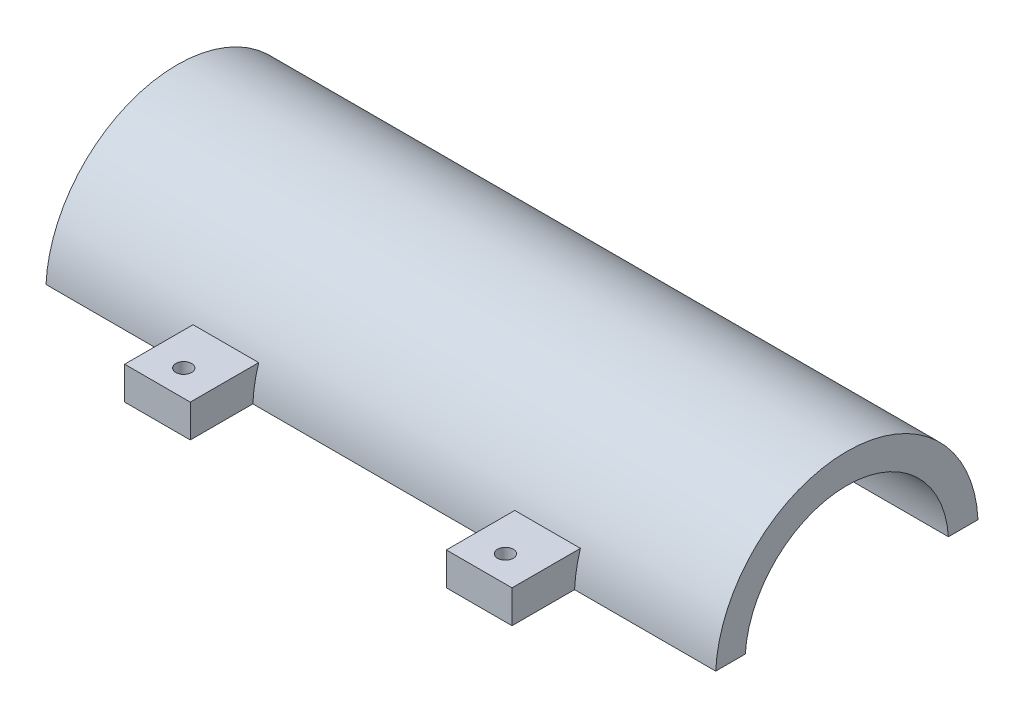
from build123d import *
from build123d.topology import SkipClean

# Parameters (mm, degrees)
SKETCH1_W                = 34
SKETCH1_H                = 30
BOSS_EXTRUDE2_DEPTH      = 51
SKETCH3_R                = 2.55
CUT_EXTRUDE3_DEPTH       = 10
SKETCH5_R                = 7.75
CUT_EXTRUDE4_DEPTH       = 51
SKETCH6_W                = 7
SKETCH6_H                = 30
CUT_EXTRUDE6_DEPTH       = 51
CUT_EXTRUDE7_DEPTH       = 51
CUT_EXTRUDE9_DEPTH       = 1.5
CUT_EXTRUDE9_DEPTH_BACK  = 1.5
BOSS_EXTRUDE5_DEPTH      = 51
CUT_EXTRUDE10_DEPTH      = 13
CUT_EXTRUDE11_START      = -13
CUT_EXTRUDE11_DEPTH      = 13
SKETCH13_W               = 2
SKETCH13_H               = 6
CUT_EXTRUDE12_DEPTH      = 2
CUT_EXTRUDE13_DEPTH      = 13
CUT_EXTRUDE13_DEPTH_BACK = 11
BOSS_EXTRUDE6_DEPTH      = 2.25
BOSS_EXTRUDE7_DEPTH      = 2.25
BOSS_EXTRUDE8_DEPTH      = 2.25
BOSS_EXTRUDE9_DEPTH      = 2.25
SKETCH22_W               = 5
SKETCH22_H               = 6
BOSS_EXTRUDE10_DEPTH     = 1
SKETCH24_W               = 5
SKETCH24_H               = 6
BOSS_EXTRUDE11_DEPTH     = 1
SKETCH25_R               = 0.6
CUT_EXTRUDE14_DEPTH      = 20
SKETCH26_R               = 2.55
BOSS_EXTRUDE12_DEPTH     = 1.5
CUT_EXTRUDE17_DEPTH      = 60


with BuildPart() as part:
    # Sketch1 → Boss-Extrude2 (new body)
    with BuildSketch(Plane(origin=(0, 0, 0), x_dir=(0, 0, -1), z_dir=(1, 0, 0))):
        with Locations((-3.945183177, 6.145902028)):
            Rectangle(SKETCH1_W, SKETCH1_H)
    extrude(amount=BOSS_EXTRUDE2_DEPTH)

    # Sketch3 → Cut-Extrude3 (cut)
    with BuildSketch(Plane(origin=(0, 0, -13.054816823), x_dir=(-1, 0, 0), z_dir=(0, 0, -1))):
        with Locations((-25.5, -1.354097972)):
            Circle(SKETCH3_R)
    extrude(amount=-CUT_EXTRUDE3_DEPTH, mode=Mode.SUBTRACT)

    # Sketch5 → Cut-Extrude4 (cut)
    with BuildSketch(Plane(origin=(51, 0, 0), x_dir=(0, 0, -1), z_dir=(1, 0, 0))):
        with Locations((-3.945183177, 1.145902028)):
            Circle(SKETCH5_R)
    extrude(amount=-CUT_EXTRUDE4_DEPTH, mode=Mode.SUBTRACT)

    # Sketch6 → Cut-Extrude6 (cut)
    with BuildSketch(Plane(origin=(51, 0, 0), x_dir=(0, 0, -1), z_dir=(1, 0, 0))):
        with Locations((9.554816823, 6.145902028)):
            Rectangle(SKETCH6_W, SKETCH6_H)
    extrude(amount=-CUT_EXTRUDE6_DEPTH, mode=Mode.SUBTRACT)

    # Sketch7 → Cut-Extrude7 (cut)
    with BuildSketch(Plane(origin=(51, 0, 0), x_dir=(0, 0, -1), z_dir=(1, 0, 0))):
        with BuildLine():
            Line((-3.945183177, -8.854097972), (-20.945183177, -8.854097972))
            Line((-20.945183177, -8.854097972), (-20.945183177, 21.145902028))
            Line((-20.945183177, 21.145902028), (6.054816823, 21.145902028))
            Line((6.054816823, 21.145902028), (6.054816823, 1.145902028))
            ThreePointArc((6.054816823, 1.145902028), (-11.016250989, 8.21696984), (-3.945183177, -8.854097972))
        make_face()
    extrude(amount=-CUT_EXTRUDE7_DEPTH, mode=Mode.SUBTRACT)

    # Sketch8 → Cut-Extrude9 (cut, two sides: drawn at the far end of the back side and taken through both)
    with BuildSketch(Plane(origin=(0, 0, -3.054816823), x_dir=(-1, 0, 0), z_dir=(0, 0, -1)).offset(-CUT_EXTRUDE9_DEPTH_BACK)):
        Polygon((-21.75, -2.180131646), (-21.75, -4.904097972), (-29.25, -4.904097972), (-29.25, -2.180131646), (-29.25, 2.195902028), (-21.75, 2.195902028), align=None)
    extrude(amount=CUT_EXTRUDE9_DEPTH + CUT_EXTRUDE9_DEPTH_BACK, mode=Mode.SUBTRACT)

    # Sketch10 → Boss-Extrude5 (add)
    with BuildSketch(Plane(origin=(51, 0, 0), x_dir=(0, 0, -1), z_dir=(1, 0, 0))):
        Polygon((-17.695183177, 1.145902028), (-17.695183177, 4.145902028), (-11.695183177, 4.145902028), (-11.695183177, 1.145902028), (-11.695183177, -1.854097972), (-17.695183177, -1.854097972), align=None)
    extrude(amount=-BOSS_EXTRUDE5_DEPTH)

    # Sketch11 → Cut-Extrude10 (cut)
    with BuildSketch(Plane(origin=(51, 0, 0), x_dir=(0, 0, -1), z_dir=(1, 0, 0))):
        with BuildLine():
            Line((-13.484575191, -1.854097972), (-17.695183177, -1.854097972))
            Line((-17.695183177, -1.854097972), (-17.695183177, 4.145902028))
            Line((-17.695183177, 4.145902028), (-13.484575191, 4.145902028))
            ThreePointArc((-13.484575191, 4.145902028), (-13.945183177, 1.145902028), (-13.484575191, -1.854097972))
        make_face()
    extrude(amount=-CUT_EXTRUDE10_DEPTH, mode=Mode.SUBTRACT)

    # Sketch12 → Cut-Extrude11 (cut)
    with BuildSketch(Plane.ZY.offset(CUT_EXTRUDE11_START)):
        with BuildLine():
            Line((13.484575191, -1.854097972), (17.695183177, -1.854097972))
            Line((17.695183177, -1.854097972), (17.695183177, 4.145902028))
            Line((17.695183177, 4.145902028), (13.484575191, 4.145902028))
            ThreePointArc((13.484575191, 4.145902028), (13.945183177, 1.145902028), (13.484575191, -1.854097972))
        make_face()
    extrude(amount=CUT_EXTRUDE11_DEPTH, mode=Mode.SUBTRACT)

    # Sketch13 → Cut-Extrude12 (cut)
    with BuildSketch(Plane.XY.offset(17.695183177)):
        with Locations((25.5, 1.145902028)):
            Rectangle(SKETCH13_W, SKETCH13_H)
    extrude(amount=-CUT_EXTRUDE12_DEPTH, mode=Mode.SUBTRACT)

    # Sketch15 → Cut-Extrude13 (cut, two sides: drawn at the far end of the back side and taken through both)
    with SkipClean():  # the faces are left unmerged after this step: merging them gives an invalid solid
        with BuildSketch(Plane(origin=(24.5, 0, 0), x_dir=(0, 0, -1), z_dir=(1, 0, 0)).offset(-CUT_EXTRUDE13_DEPTH_BACK)):
            with BuildLine():
                Line((-17.695183177, 4.145902028), (-17.695183177, -1.854097972))
                Line((-17.695183177, -1.854097972), (-13.484575191, -1.854097972))
                ThreePointArc((-13.484575191, -1.854097972), (-13.945183177, 1.145902028), (-13.484575191, 4.145902028))
                Line((-13.484575191, 4.145902028), (-17.695183177, 4.145902028))
            make_face()
        extrude(amount=CUT_EXTRUDE13_DEPTH + CUT_EXTRUDE13_DEPTH_BACK, mode=Mode.SUBTRACT)

    # Sketch17 → Boss-Extrude6 (add)
    with SkipClean():  # the faces are left unmerged after this step: merging them gives an invalid solid
        with BuildSketch(Plane(origin=(38, 0, 0), x_dir=(0, 0, -1), z_dir=(1, 0, 0))):
            with BuildLine():
                Line((-13.484575191, 4.145902028), (-17.695183177, 4.145902028))
                Line((-17.695183177, 4.145902028), (-17.695183177, -1.854097972))
                Line((-17.695183177, -1.854097972), (-13.484575191, -1.854097972))
                ThreePointArc((-13.484575191, -1.854097972), (-13.945183177, 1.145902028), (-13.484575191, 4.145902028))
            make_face()
        extrude(amount=BOSS_EXTRUDE6_DEPTH)

    # Sketch19 → Boss-Extrude7 (add)
    with SkipClean():  # the faces are left unmerged after this step: merging them gives an invalid solid
        with BuildSketch(Plane.ZY.offset(-13)):
            with BuildLine():
                Line((13.484575191, 4.145902028), (17.695183177, 4.145902028))
                Line((17.695183177, 4.145902028), (17.695183177, -1.854097972))
                Line((17.695183177, -1.854097972), (13.484575191, -1.854097972))
                ThreePointArc((13.484575191, -1.854097972), (13.945183177, 1.145902028), (13.484575191, 4.145902028))
            make_face()
        extrude(amount=BOSS_EXTRUDE7_DEPTH)

    # Sketch20 → Boss-Extrude8 (add)
    with SkipClean():  # the faces are left unmerged after this step: merging them gives an invalid solid
        with BuildSketch(Plane(origin=(13.5, 0, 0), x_dir=(0, 0, -1), z_dir=(1, 0, 0))):
            with BuildLine():
                Line((-17.695183177, -1.854097972), (-17.695183177, 4.145902028))
                Line((-17.695183177, 4.145902028), (-13.484575191, 4.145902028))
                ThreePointArc((-13.484575191, 4.145902028), (-13.945183177, 1.145902028), (-13.484575191, -1.854097972))
                Line((-13.484575191, -1.854097972), (-17.695183177, -1.854097972))
            make_face()
        extrude(amount=BOSS_EXTRUDE8_DEPTH)

    # Sketch21 → Boss-Extrude9 (add)
    with SkipClean():  # the faces are left unmerged after this step: merging them gives an invalid solid
        with BuildSketch(Plane.ZY.offset(-37.5)):
            with BuildLine():
                Line((13.484575191, 4.145902028), (17.695183177, 4.145902028))
                Line((17.695183177, 4.145902028), (17.695183177, -1.854097972))
                Line((17.695183177, -1.854097972), (13.484575191, -1.854097972))
                ThreePointArc((13.484575191, -1.854097972), (13.945183177, 1.145902028), (13.484575191, 4.145902028))
            make_face()
        extrude(amount=BOSS_EXTRUDE9_DEPTH)

    # Sketch22 → Boss-Extrude10 (add)
    with SkipClean():  # the faces are left unmerged after this step: merging them gives an invalid solid
        with BuildSketch(Plane.XY.offset(17.695183177)):
            with Locations((37.75, 1.145902028)):
                Rectangle(SKETCH22_W, SKETCH22_H)
        extrude(amount=BOSS_EXTRUDE10_DEPTH)

    # Sketch24 → Boss-Extrude11 (add)
    with SkipClean():  # the faces are left unmerged after this step: merging them gives an invalid solid
        with BuildSketch(Plane.XY.offset(17.695183177)):
            with Locations((13.25, 1.145902028)):
                Rectangle(SKETCH24_W, SKETCH24_H)
        extrude(amount=BOSS_EXTRUDE11_DEPTH)

    # Sketch25 → Cut-Extrude14 (cut)
    with SkipClean():  # the faces are left unmerged after this step: merging them gives an invalid solid
        with BuildSketch(Plane(origin=(0, 4.145902028, 0), x_dir=(1, 0, 0), z_dir=(0, 1, 0))):
            with Locations((13.25, -16.695183177)):
                Circle(SKETCH25_R)
            with Locations((37.75, -16.695183177)):
                Circle(SKETCH25_R)
        extrude(amount=-CUT_EXTRUDE14_DEPTH, mode=Mode.SUBTRACT)

    # Sketch26 → Boss-Extrude12 (add)
    with SkipClean():  # the faces are left unmerged after this step: merging them gives an invalid solid
        with BuildSketch(Plane(origin=(0, 0, -6.054816823), x_dir=(-1, 0, 0), z_dir=(0, 0, -1))):
            with Locations((-25.5, -1.354097972)):
                Circle(SKETCH26_R)
        extrude(amount=-BOSS_EXTRUDE12_DEPTH)

    # Sketch27 → Cut-Extrude17 (cut)
    with SkipClean():  # the faces are left unmerged after this step: merging them gives an invalid solid
        with BuildSketch(Plane(origin=(51, 0, 0), x_dir=(0, 0, -1), z_dir=(1, 0, 0))):
            Polygon((-18.695183177, 1.145902028), (-18.695183177, 1.645902028), (6.594766684, 1.645902028), (6.594766684, 1.145902028), (6.594766684, 0.645902028), (6.594766684, -9.845584232), (-18.695183177, -9.845584232), (-18.695183177, 0.645902028), align=None)
        extrude(amount=-CUT_EXTRUDE17_DEPTH, mode=Mode.SUBTRACT)


solid = part.part
